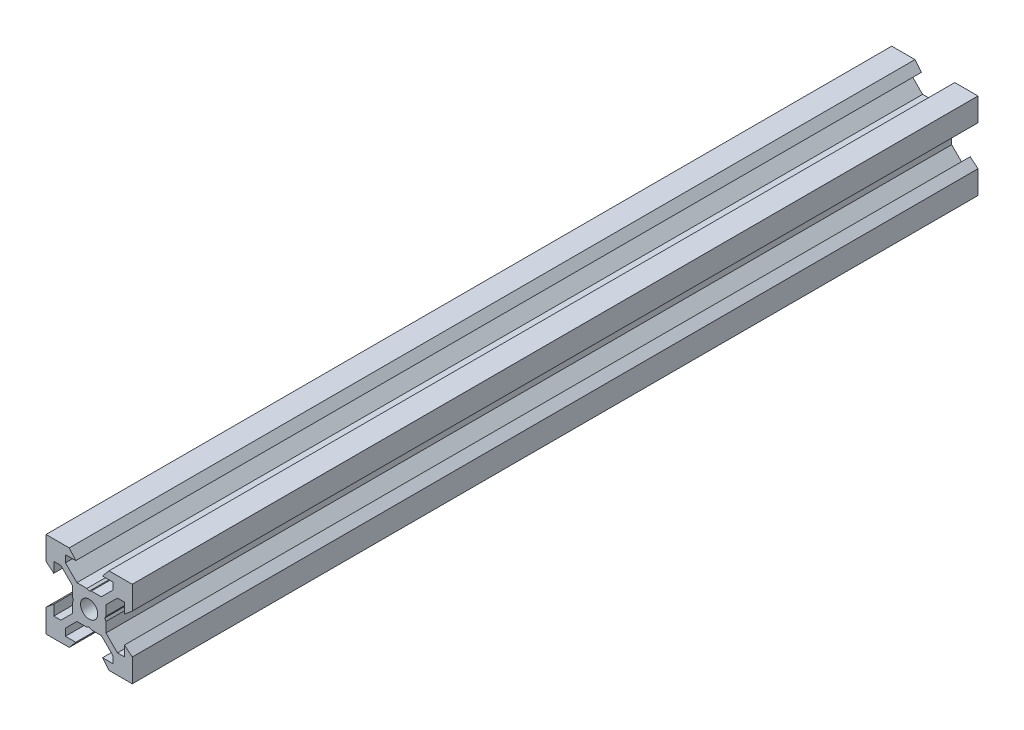
from build123d import *

# Parameters (mm, degrees)
SKETCH1_R           = 2
BOSS_EXTRUDE1_DEPTH = 196.09


with BuildPart() as part:
    # Sketch1 → Boss-Extrude1 (new body)
    with BuildSketch(Plane.XY):
        Polygon((10, 10), (10, 4.610379336), (8.2, 3.1), (8.2, 5.5), (6.560660172, 5.5), (3.9, 2.839339828), (3.9, 0.519615242), (3.6, 0), (3.9, -0.519615242), (3.9, -2.839339828), (6.560660172, -5.5), (8.2, -5.5), (8.2, -3.1), (10, -4.610379336), (10, -10), (4.610379336, -10), (3.1, -8.2), (5.5, -8.2), (5.5, -6.560660172), (2.839339828, -3.9), (0.519615242, -3.9), (0, -3.6), (-0.519615242, -3.9), (-2.839339828, -3.9), (-5.5, -6.560660172), (-5.5, -8.2), (-3.1, -8.2), (-4.610379336, -10), (-10, -10), (-10, -4.610379336), (-8.2, -3.1), (-8.2, -5.5), (-6.560660172, -5.5), (-3.9, -2.839339828), (-3.9, -0.519615242), (-3.6, 0), (-3.9, 0.519615242), (-3.9, 2.839339828), (-6.560660172, 5.5), (-8.2, 5.5), (-8.2, 3.1), (-10, 4.610379336), (-10, 10), (-4.610379336, 10), (-3.1, 8.2), (-5.5, 8.2), (-5.5, 6.560660172), (-2.839339828, 3.9), (-0.519615242, 3.9), (0, 3.6), (0.519615242, 3.9), (2.839339828, 3.9), (5.5, 6.560660172), (5.5, 8.2), (3.1, 8.2), (4.610379336, 10), align=None)
        Circle(SKETCH1_R, mode=Mode.SUBTRACT)
    extrude(amount=BOSS_EXTRUDE1_DEPTH)


solid = part.part
